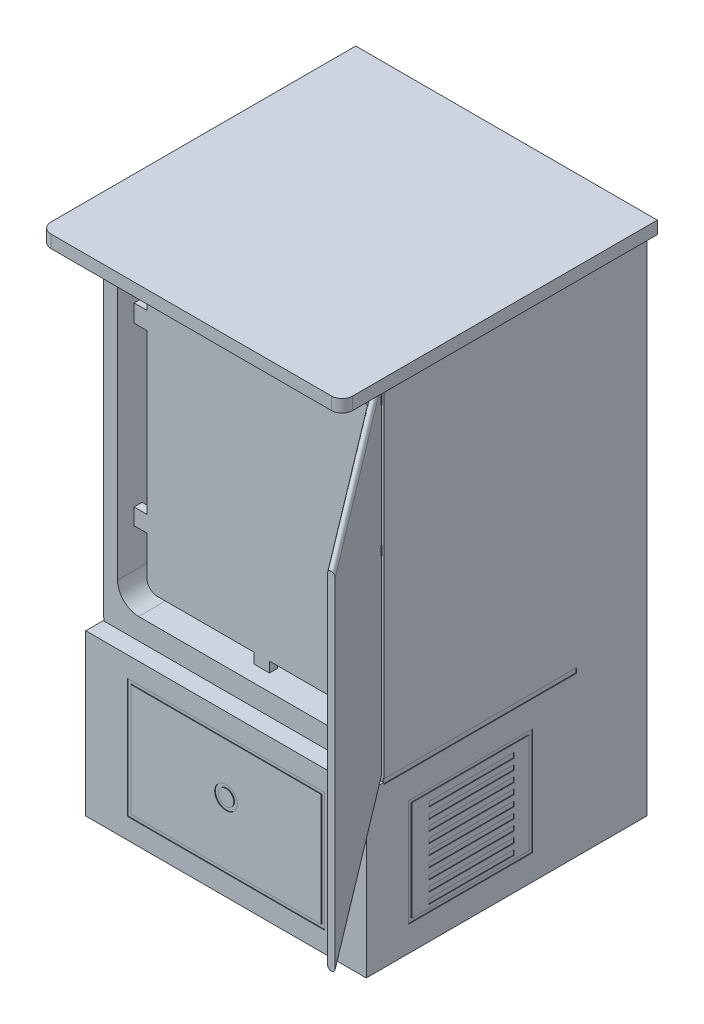
from build123d import *

# Parameters (mm, degrees)
CROQUIS1_W                = 800
CROQUIS1_H                = 600
SALIENTE_EXTRUIR1_DEPTH   = 1000
CORTAR_EXTRUIR1_DEPTH     = 567
CROQUIS3_W                = 800
CROQUIS3_H                = 35.957768847
SALIENTE_EXTRUIR2_DEPTH   = 99
CROQUIS4_W                = 699
CROQUIS4_H                = 35.957768847
SALIENTE_EXTRUIR3_DEPTH   = 30
CROQUIS5_W                = 699
CROQUIS5_H                = 35.957768847
SALIENTE_EXTRUIR4_DEPTH   = 30
REDONDEO1_R               = 30
CROQUIS6_W                = 800
CROQUIS6_H                = 486.805991466
SALIENTE_EXTRUIR5_DEPTH   = 600
CROQUIS8_W                = 800
CROQUIS8_H                = 993.182062535
CORTAR_EXTRUIR3_DEPTH     = 50
CROQUIS9_W                = 550
CROQUIS9_H                = 13.666207369
CORTAR_EXTRUIR4_DEPTH     = 2
CROQUIS10_W               = 550
CROQUIS10_H               = 13.666207369
CORTAR_EXTRUIR5_DEPTH     = 2
CROQUIS11_W               = 354.416964099
CROQUIS11_H               = 305.343845993
CROQUIS11_W_2             = 334.416964099
CROQUIS11_H_2             = 285.343845993
CORTAR_EXTRUIR6_DEPTH     = 2
CROQUIS12_W               = 354.416964099
CROQUIS12_H               = 305.343845993
CROQUIS12_W_2             = 334.416964099
CROQUIS12_H_2             = 285.343845993
CORTAR_EXTRUIR7_DEPTH     = 2
CROQUIS13_W               = 243.309624206
CROQUIS13_H               = 13.939613887
CORTAR_EXTRUIR8_DEPTH     = 2
MATRIZL1_COUNT            = 9
MATRIZL1_PITCH            = 30
SIMETR_A1_COPY_1_SKETCH_W = 243.309624206
SIMETR_A1_COPY_1_SKETCH_H = 13.939613887
SIMETR_A1_COPY_1_DEPTH    = 2
SIMETR_A1_COPY_2_SKETCH_W = 243.309624206
SIMETR_A1_COPY_2_SKETCH_H = 13.939613887
SIMETR_A1_COPY_2_DEPTH    = 2
SIMETR_A1_COPY_3_SKETCH_W = 243.309624206
SIMETR_A1_COPY_3_SKETCH_H = 13.939613887
SIMETR_A1_COPY_3_DEPTH    = 2
SIMETR_A1_COPY_4_SKETCH_W = 243.309624206
SIMETR_A1_COPY_4_SKETCH_H = 13.939613887
SIMETR_A1_COPY_4_DEPTH    = 2
SIMETR_A1_COPY_5_SKETCH_W = 243.309624206
SIMETR_A1_COPY_5_SKETCH_H = 13.939613887
SIMETR_A1_COPY_5_DEPTH    = 2
SIMETR_A1_COPY_6_SKETCH_W = 243.309624206
SIMETR_A1_COPY_6_SKETCH_H = 13.939613887
SIMETR_A1_COPY_6_DEPTH    = 2
SIMETR_A1_COPY_7_SKETCH_W = 243.309624206
SIMETR_A1_COPY_7_SKETCH_H = 13.939613887
SIMETR_A1_COPY_7_DEPTH    = 2
SIMETR_A1_COPY_8_SKETCH_W = 243.309624206
SIMETR_A1_COPY_8_SKETCH_H = 13.939613887
SIMETR_A1_COPY_8_DEPTH    = 2
CROQUIS14_W               = 563.20495413
CROQUIS14_H               = 340.598481742
CROQUIS14_W_2             = 543.20495413
CROQUIS14_H_2             = 320.598481742
CORTAR_EXTRUIR9_DEPTH     = 2
CROQUIS15_R               = 32.209771252
CROQUIS15_R_2             = 22.209771252
CORTAR_EXTRUIR10_DEPTH    = 2
CROQUIS18_W               = 34.691743086
CROQUIS18_H               = 30.529625404
CROQUIS18_W_2             = 44.468602639
CROQUIS18_H_2             = 33.523883017
CROQUIS18_H_3             = 26.695345902
SALIENTE_EXTRUIR6_DEPTH   = 22
REDONDEO2_R               = 19
CORTAR_EXTRUIR11_DEPTH    = 3
CROQUIS20_W               = 44.562430694
CROQUIS20_H               = 46.694432352
CROQUIS20_H_2             = 35.984257535
CROQUIS20_W_2             = 73.041407783
CROQUIS20_H_3             = 49.656905024
CROQUIS20_H_4             = 46.208188546
CROQUIS20_W_3             = 57.507633586
CROQUIS20_H_5             = 75.965991012
CROQUIS20_W_4             = 44.486501302
CROQUIS20_H_6             = 58.796125296
SALIENTE_EXTRUIR7_DEPTH   = 23
CROQUIS21_W               = 535.403782416
CROQUIS21_H               = 17.835231245
SALIENTE_EXTRUIR8_DEPTH   = 218
SALIENTE_EXTRUIR9_DEPTH   = 200


with BuildPart() as part:
    # Croquis1 → Saliente-Extruir1 (new body)
    with BuildSketch(Plane(origin=(0, 0, 0), x_dir=(1, 0, 0), z_dir=(0, 1, 0))):
        Rectangle(CROQUIS1_W, CROQUIS1_H)
    extrude(amount=SALIENTE_EXTRUIR1_DEPTH)

    # Croquis2 → Cortar-Extruir1 (cut)
    with BuildSketch(Plane.XY.offset(300)):
        with BuildLine():
            Line((-299.259727569, 934.483814363), (294.27207392, 934.483814363))
            ThreePointArc((294.27207392, 934.483814363), (336.698480791, 916.910221234), (354.27207392, 874.483814363))
            Line((354.27207392, 874.483814363), (354.27207392, 91.459739531))
            ThreePointArc((354.27207392, 91.459739531), (336.698480791, 49.03333266), (294.27207392, 31.459739531))
            Line((294.27207392, 31.459739531), (-299.259727569, 31.459739531))
            ThreePointArc((-299.259727569, 31.459739531), (-341.68613444, 49.03333266), (-359.259727569, 91.459739531))
            Line((-359.259727569, 91.459739531), (-359.259727569, 874.483814363))
            ThreePointArc((-359.259727569, 874.483814363), (-341.68613444, 916.910221234), (-299.259727569, 934.483814363))
        make_face()
    extrude(amount=-CORTAR_EXTRUIR1_DEPTH, mode=Mode.SUBTRACT)

    # Croquis3 → Saliente-Extruir2 (add)
    with BuildSketch(Plane.XY.offset(300)):
        with Locations((0, 982.021115577)):
            Rectangle(CROQUIS3_W, CROQUIS3_H)
    extrude(amount=SALIENTE_EXTRUIR2_DEPTH)

    # Croquis4 → Saliente-Extruir3 (add)
    with BuildSketch(Plane(origin=(400, 0, 0), x_dir=(0, 0, -1), z_dir=(1, 0, 0))):
        with Locations((-49.5, 982.021115577)):
            Rectangle(CROQUIS4_W, CROQUIS4_H)
    extrude(amount=SALIENTE_EXTRUIR3_DEPTH)

    # Croquis5 → Saliente-Extruir4 (add)
    with BuildSketch(Plane.ZY.offset(400)):
        with Locations((49.5, 982.021115577)):
            Rectangle(CROQUIS5_W, CROQUIS5_H)
    extrude(amount=SALIENTE_EXTRUIR4_DEPTH)

    # Redondeo1
    redondeo1_edges = [part.edges().sort_by_distance(p)[0] for p in [
        (430, 982.021115577, 399),
        (-430, 982.021115577, 399),
    ]]
    fillet(redondeo1_edges, radius=REDONDEO1_R)

    # Croquis6 → Saliente-Extruir5 (add)
    with BuildSketch(Plane(origin=(0, 0, -300), x_dir=(-1, 0, 0), z_dir=(0, 0, -1))):
        with Locations((0, -243.402995733)):
            Rectangle(CROQUIS6_W, CROQUIS6_H)
    extrude(amount=-SALIENTE_EXTRUIR5_DEPTH)

    # Croquis8 → Cortar-Extruir3 (cut)
    with BuildSketch(Plane.XY.offset(300)):
        with Locations((0, 467.451199886)):
            Rectangle(CROQUIS8_W, CROQUIS8_H)
    extrude(amount=-CORTAR_EXTRUIR3_DEPTH, mode=Mode.SUBTRACT)

    # Croquis9 → Cortar-Extruir4 (cut)
    with BuildSketch(Plane.ZY.offset(400)):
        with Locations((-25, -27.151049572)):
            Rectangle(CROQUIS9_W, CROQUIS9_H)
    extrude(amount=-CORTAR_EXTRUIR4_DEPTH, mode=Mode.SUBTRACT)

    # Croquis10 → Cortar-Extruir5 (cut)
    with BuildSketch(Plane(origin=(400, 0, 0), x_dir=(0, 0, -1), z_dir=(1, 0, 0))):
        with Locations((25, -27.151049572)):
            Rectangle(CROQUIS10_W, CROQUIS10_H)
    extrude(amount=-CORTAR_EXTRUIR5_DEPTH, mode=Mode.SUBTRACT)

    # Croquis11 → Cortar-Extruir6 (cut)
    with BuildSketch(Plane.ZY.offset(400)):
        with Locations((2.727596994, -261.728327175)):
            Rectangle(CROQUIS11_W, CROQUIS11_H)
        with Locations((2.727596994, -261.728327175)):
            Rectangle(CROQUIS11_W_2, CROQUIS11_H_2, mode=Mode.SUBTRACT)
    extrude(amount=-CORTAR_EXTRUIR6_DEPTH, mode=Mode.SUBTRACT)

    # Croquis12 → Cortar-Extruir7 (cut)
    with BuildSketch(Plane(origin=(400, 0, 0), x_dir=(0, 0, -1), z_dir=(1, 0, 0))):
        with Locations((-2.727596994, -261.728327175)):
            Rectangle(CROQUIS12_W, CROQUIS12_H)
        with Locations((-2.727596994, -261.728327175)):
            Rectangle(CROQUIS12_W_2, CROQUIS12_H_2, mode=Mode.SUBTRACT)
    extrude(amount=-CORTAR_EXTRUIR7_DEPTH, mode=Mode.SUBTRACT)

    # Croquis13 → Cortar-Extruir8 (cut)
    with BuildSketch(Plane.ZY.offset(400)):
        with Locations((-0.370526782, -147.593668647)):
            Rectangle(CROQUIS13_W, CROQUIS13_H)
    cortar_extruir8 = extrude(amount=-CORTAR_EXTRUIR8_DEPTH, mode=Mode.SUBTRACT)

    # MatrizL1: Cortar-Extruir8 ×9
    with Locations(*[(0, -i * MATRIZL1_PITCH, 0) for i in range(1, MATRIZL1_COUNT)]):
        add(cortar_extruir8, mode=Mode.SUBTRACT)

    # Simetría1: Cortar-Extruir8 across plane
    add(cortar_extruir8.mirror(Plane(origin=(0, 0, 0), x_dir=(0, 0, 1), z_dir=(1, 0, 0))), mode=Mode.SUBTRACT)

    # Simetría1 copy 1 sketch → Simetría1 copy 1 (cut)
    with BuildSketch(Plane(origin=(400, -30, 0), x_dir=(0, 0, 1), z_dir=(1, 0, 0))):
        with Locations((-0.370526782, 147.593668647)):
            Rectangle(SIMETR_A1_COPY_1_SKETCH_W, SIMETR_A1_COPY_1_SKETCH_H)
    extrude(amount=-SIMETR_A1_COPY_1_DEPTH, mode=Mode.SUBTRACT)

    # Simetría1 copy 2 sketch → Simetría1 copy 2 (cut)
    with BuildSketch(Plane(origin=(400, -60, 0), x_dir=(0, 0, 1), z_dir=(1, 0, 0))):
        with Locations((-0.370526782, 147.593668647)):
            Rectangle(SIMETR_A1_COPY_2_SKETCH_W, SIMETR_A1_COPY_2_SKETCH_H)
    extrude(amount=-SIMETR_A1_COPY_2_DEPTH, mode=Mode.SUBTRACT)

    # Simetría1 copy 3 sketch → Simetría1 copy 3 (cut)
    with BuildSketch(Plane(origin=(400, -90, 0), x_dir=(0, 0, 1), z_dir=(1, 0, 0))):
        with Locations((-0.370526782, 147.593668647)):
            Rectangle(SIMETR_A1_COPY_3_SKETCH_W, SIMETR_A1_COPY_3_SKETCH_H)
    extrude(amount=-SIMETR_A1_COPY_3_DEPTH, mode=Mode.SUBTRACT)

    # Simetría1 copy 4 sketch → Simetría1 copy 4 (cut)
    with BuildSketch(Plane(origin=(400, -120, 0), x_dir=(0, 0, 1), z_dir=(1, 0, 0))):
        with Locations((-0.370526782, 147.593668647)):
            Rectangle(SIMETR_A1_COPY_4_SKETCH_W, SIMETR_A1_COPY_4_SKETCH_H)
    extrude(amount=-SIMETR_A1_COPY_4_DEPTH, mode=Mode.SUBTRACT)

    # Simetría1 copy 5 sketch → Simetría1 copy 5 (cut)
    with BuildSketch(Plane(origin=(400, -150, 0), x_dir=(0, 0, 1), z_dir=(1, 0, 0))):
        with Locations((-0.370526782, 147.593668647)):
            Rectangle(SIMETR_A1_COPY_5_SKETCH_W, SIMETR_A1_COPY_5_SKETCH_H)
    extrude(amount=-SIMETR_A1_COPY_5_DEPTH, mode=Mode.SUBTRACT)

    # Simetría1 copy 6 sketch → Simetría1 copy 6 (cut)
    with BuildSketch(Plane(origin=(400, -180, 0), x_dir=(0, 0, 1), z_dir=(1, 0, 0))):
        with Locations((-0.370526782, 147.593668647)):
            Rectangle(SIMETR_A1_COPY_6_SKETCH_W, SIMETR_A1_COPY_6_SKETCH_H)
    extrude(amount=-SIMETR_A1_COPY_6_DEPTH, mode=Mode.SUBTRACT)

    # Simetría1 copy 7 sketch → Simetría1 copy 7 (cut)
    with BuildSketch(Plane(origin=(400, -210, 0), x_dir=(0, 0, 1), z_dir=(1, 0, 0))):
        with Locations((-0.370526782, 147.593668647)):
            Rectangle(SIMETR_A1_COPY_7_SKETCH_W, SIMETR_A1_COPY_7_SKETCH_H)
    extrude(amount=-SIMETR_A1_COPY_7_DEPTH, mode=Mode.SUBTRACT)

    # Simetría1 copy 8 sketch → Simetría1 copy 8 (cut)
    with BuildSketch(Plane(origin=(400, -240, 0), x_dir=(0, 0, 1), z_dir=(1, 0, 0))):
        with Locations((-0.370526782, 147.593668647)):
            Rectangle(SIMETR_A1_COPY_8_SKETCH_W, SIMETR_A1_COPY_8_SKETCH_H)
    extrude(amount=-SIMETR_A1_COPY_8_DEPTH, mode=Mode.SUBTRACT)

    # Croquis14 → Cortar-Extruir9 (cut)
    with BuildSketch(Plane.XY.offset(300)):
        with Locations((0, -257.972911424)):
            Rectangle(CROQUIS14_W, CROQUIS14_H)
        with Locations((0, -257.972911424)):
            Rectangle(CROQUIS14_W_2, CROQUIS14_H_2, mode=Mode.SUBTRACT)
    extrude(amount=-CORTAR_EXTRUIR9_DEPTH, mode=Mode.SUBTRACT)

    # Croquis15 → Cortar-Extruir10 (cut)
    with BuildSketch(Plane.XY.offset(300)):
        with Locations((0, -241.078346398)):
            Circle(CROQUIS15_R)
        with Locations((0, -241.078346398)):
            Circle(CROQUIS15_R_2, mode=Mode.SUBTRACT)
    extrude(amount=-CORTAR_EXTRUIR10_DEPTH, mode=Mode.SUBTRACT)

    # Barrer1: sweep along a curve in space
    with BuildLine() as barrer1_path:
        Line((381.946438311, 467.235507916, 250), (793.481110183, 467.318527679, 793.146863733))
    # Croquis17 → Barrer1 (sweep)
    with BuildSketch(Plane.XY.offset(250)):
        with BuildLine():
            Line((392.862198364, 950.092677746), (392.862198364, -15.621661914))
            ThreePointArc((392.862198364, -15.621661914), (381.946438311, -26.537421967), (371.030678258, -15.621661914))
            Line((371.030678258, -15.621661914), (371.030678258, 950.092677746))
            ThreePointArc((371.030678258, 950.092677746), (381.946438311, 961.0084378), (392.862198364, 950.092677746))
        make_face()
    sweep(path=barrer1_path.line)

    # Croquis18 → Saliente-Extruir6 (add)
    with BuildSketch(Plane.XY.offset(250)):
        with Locations((377.357040996, 915.688026457)):
            Rectangle(CROQUIS18_W, CROQUIS18_H)
        with Locations((368.316814459, 6.739425021)):
            Rectangle(CROQUIS18_W_2, CROQUIS18_H_2)
        with Locations((377.357040996, 540.796431256)):
            Rectangle(CROQUIS18_W, CROQUIS18_H_3)
    extrude(amount=SALIENTE_EXTRUIR6_DEPTH)

    # Redondeo2
    redondeo2_edges = [part.edges().sort_by_distance(p)[0] for p in [
        (360.011169453, 915.688026457, 272),
        (346.082513139, 6.739425021, 272),
        (360.011169453, 540.796431256, 272),
    ]]
    fillet(redondeo2_edges, radius=REDONDEO2_R)

    # Croquis19 → Cortar-Extruir11 (cut)
    with BuildSketch(Plane(origin=(115.374267512, 0, -87.417445434), x_dir=(0.603913419, 0, 0.797049925), z_dir=(-0.797049925, 0, 0.603913419))):
        with BuildLine():
            Line((515.246456877, 6.925848235), (1050.984048336, 6.925848235))
            ThreePointArc((1050.984048336, 6.925848235), (1072.197251772, 15.712644799), (1080.984048336, 36.925848235))
            Line((1080.984048336, 36.925848235), (1080.984048336, 894.163276302))
            ThreePointArc((1080.984048336, 894.163276302), (1072.197251772, 915.376479738), (1050.984048336, 924.163276302))
            Line((1050.984048336, 924.163276302), (515.246456877, 924.163276302))
            ThreePointArc((515.246456877, 924.163276302), (494.033253441, 915.376479738), (485.246456877, 894.163276302))
            Line((485.246456877, 894.163276302), (485.246456877, 36.925848235))
            ThreePointArc((485.246456877, 36.925848235), (494.033253441, 15.712644799), (515.246456877, 6.925848235))
        make_face()
        with BuildLine():
            Line((495.246456877, 46.925848235), (495.246456877, 884.163276302))
            ThreePointArc((495.246456877, 884.163276302), (504.033253441, 905.376479738), (525.246456877, 914.163276302))
            Line((525.246456877, 914.163276302), (1040.984048336, 914.163276302))
            ThreePointArc((1040.984048336, 914.163276302), (1062.197251772, 905.376479738), (1070.984048336, 884.163276302))
            Line((1070.984048336, 884.163276302), (1070.984048336, 46.925848235))
            ThreePointArc((1070.984048336, 46.925848235), (1062.197251772, 25.712644799), (1040.984048336, 16.925848235))
            Line((1040.984048336, 16.925848235), (525.246456877, 16.925848235))
            ThreePointArc((525.246456877, 16.925848235), (504.033253441, 25.712644799), (495.246456877, 46.925848235))
        make_face(mode=Mode.SUBTRACT)
    extrude(amount=-CORTAR_EXTRUIR11_DEPTH, mode=Mode.SUBTRACT)

    # Croquis20 → Saliente-Extruir7 (add)
    with BuildSketch(Plane.XY.offset(180)):
        with BuildLine():
            Line((-292.739023677, 60.857802179), (301.990858573, 60.857802179))
            ThreePointArc((301.990858573, 60.857802179), (323.204062009, 69.644598744), (331.990858573, 90.857802179))
            Line((331.990858573, 90.857802179), (331.990858573, 866.500818857))
            ThreePointArc((331.990858573, 866.500818857), (323.204062009, 887.714022293), (301.990858573, 896.500818857))
            Line((301.990858573, 896.500818857), (-292.739023677, 896.500818857))
            ThreePointArc((-292.739023677, 896.500818857), (-313.952227113, 887.714022293), (-322.739023677, 866.500818857))
            Line((-322.739023677, 866.500818857), (-322.739023677, 90.857802179))
            ThreePointArc((-322.739023677, 90.857802179), (-313.952227113, 69.644598744), (-292.739023677, 60.857802179))
        make_face()
        with Locations((331.990858573, 727.730285012)):
            Rectangle(CROQUIS20_W, CROQUIS20_H)
        with Locations((331.990858573, 205.021757931)):
            Rectangle(CROQUIS20_W, CROQUIS20_H_2)
        with Locations((-322.739023677, 727.484970932)):
            Rectangle(CROQUIS20_W_2, CROQUIS20_H_3)
        with Locations((-322.739023677, 225.379990245)):
            Rectangle(CROQUIS20_W_2, CROQUIS20_H_4)
        with Locations((4.625917448, 896.500818857)):
            Rectangle(CROQUIS20_W_3, CROQUIS20_H_5)
        with Locations((4.625917448, 60.857802179)):
            Rectangle(CROQUIS20_W_4, CROQUIS20_H_6)
    extrude(amount=SALIENTE_EXTRUIR7_DEPTH)

    # Croquis21 → Saliente-Extruir8 (add)
    with BuildSketch(Plane.XY.offset(-267)):
        with Locations((0, 354.065407038)):
            Rectangle(CROQUIS21_W, CROQUIS21_H)
    extrude(amount=SALIENTE_EXTRUIR8_DEPTH)

    # Croquis22 → Saliente-Extruir9 (add)
    with BuildSketch(Plane(origin=(0, 0, -300), x_dir=(-1, 0, 0), z_dir=(0, 0, -1))):
        Polygon((-430, 964.042231153), (-430, 1000), (430, 1000), (430, 964.042231153), (400, 964.042231153), (400, -486.805991466), (-400, -486.805991466), (-400, 964.042231153), align=None)
    extrude(amount=SALIENTE_EXTRUIR9_DEPTH)


solid = part.part
